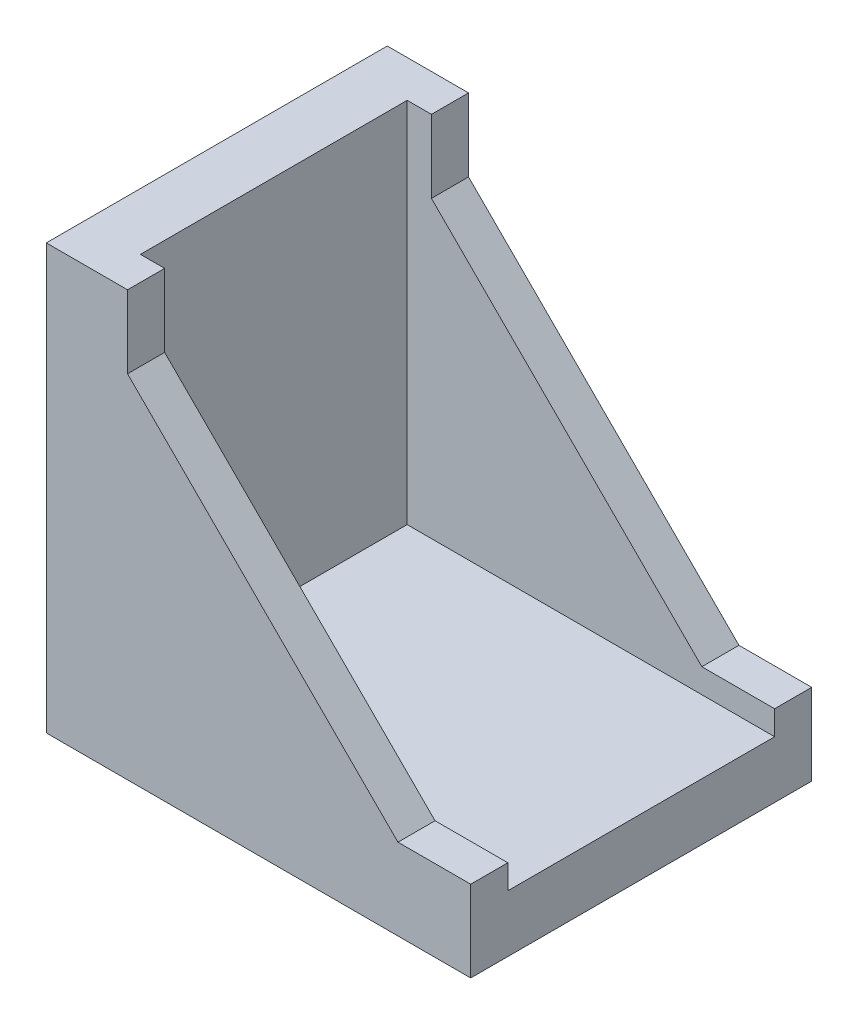
from build123d import *

# Parameters (mm, degrees)
SALIENTE_EXTRUIR1_DEPTH = 14.06
CROQUIS4_W              = 30.3
CROQUIS4_H              = 30.3
CORTAR_EXTRUIR1_DEPTH   = 11


with BuildPart() as part:
    # Croquis1 → Saliente-Extruir1 (new body, symmetric)
    with BuildSketch(Plane.XY):
        Polygon((0, 0), (0, 35), (6.7, 35), (6.7, 29), (29, 6.7), (35, 6.7), (35, 0), align=None)
    extrude(amount=SALIENTE_EXTRUIR1_DEPTH, both=True)

    # Croquis4 → Cortar-Extruir1 (cut, symmetric)
    with BuildSketch(Plane.XY):
        with Locations((19.85, 19.85)):
            Rectangle(CROQUIS4_W, CROQUIS4_H)
    extrude(amount=CORTAR_EXTRUIR1_DEPTH, both=True, mode=Mode.SUBTRACT)


solid = part.part
